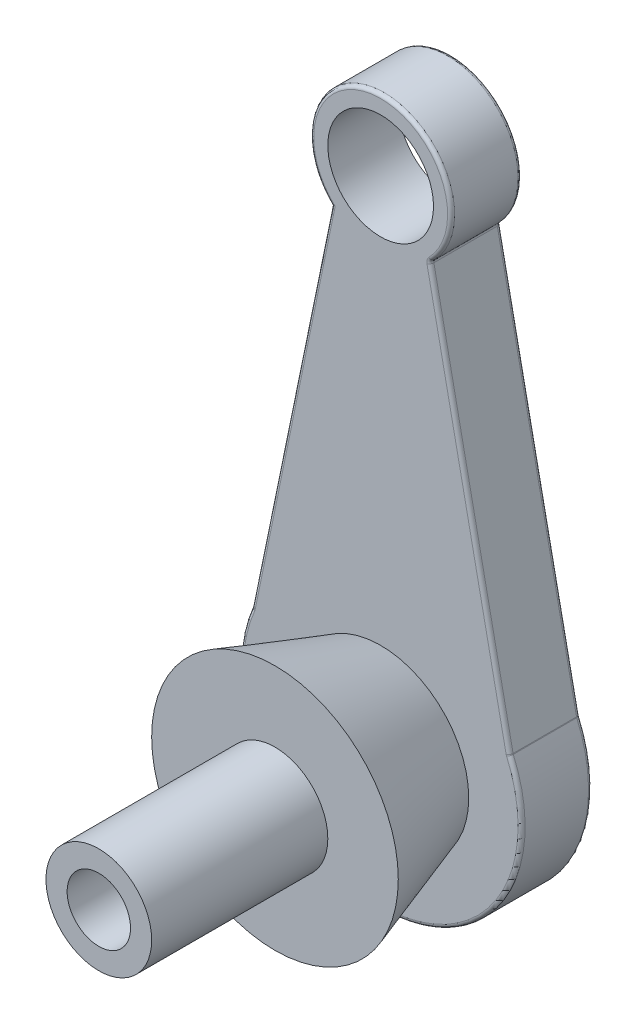
from build123d import *

# Parameters (mm, degrees)
BOSS_EXTRUDE2_DEPTH = 10
SKETCH11_R          = 7.5
CUT_EXTRUDE1_DEPTH  = 11
SKETCH12_R          = 12.5
SKETCH13_R          = 17.5
SKETCH16_R          = 7.5
BOSS_EXTRUDE3_DEPTH = 25
SKETCH17_R          = 13
CUT_EXTRUDE2_DEPTH  = 7.7
FILLET2_R           = 0.5
CUT_EXTRUDE3_REACH  = 44.3
SKETCH18_R          = 4.5


with BuildPart() as part:
    # Sketch10 → Boss-Extrude2 (new body)
    with BuildSketch(Plane.XY):
        with BuildLine():
            Line((-7, 12.658044745), (-18.304628492, -42.341955255))
            ThreePointArc((-18.304628492, -42.341955255), (0, -70.400526826), (18.304628492, -42.341955255))
            Line((18.304628492, -42.341955255), (7, 12.658044745))
            ThreePointArc((7, 12.658044745), (0, 29.799473174), (-7, 12.658044745))
        make_face()
    extrude(amount=-BOSS_EXTRUDE2_DEPTH)

    # Sketch11 → Cut-Extrude1 (cut, through all)
    with BuildSketch(Plane.XY):
        with Locations((0, 19.799473174)):
            Circle(SKETCH11_R)
    extrude(amount=-CUT_EXTRUDE1_DEPTH, mode=Mode.SUBTRACT)

    # Sketch12 → Loft1 section 0
    with BuildSketch(Plane.XY):
        with Locations((0, -50.400526826)):
            Circle(SKETCH12_R)
    # Sketch13 → Loft1 section 1
    with BuildSketch(Plane.XY.offset(15)):
        with Locations((0, -50.400526826)):
            Circle(SKETCH13_R)
    loft()

    # Sketch16 → Boss-Extrude3 (add)
    with BuildSketch(Plane.XY.offset(15)):
        with Locations((0, -50.400526826)):
            Circle(SKETCH16_R)
    extrude(amount=BOSS_EXTRUDE3_DEPTH)

    # Sketch17 → Cut-Extrude2 (cut)
    with BuildSketch(Plane(origin=(0, 0, -10), x_dir=(-1, 0, 0), z_dir=(0, 0, -1))):
        with Locations((0, -50.400526826)):
            Circle(SKETCH17_R)
    extrude(amount=-CUT_EXTRUDE2_DEPTH, mode=Mode.SUBTRACT)

    # Fillet2
    fillet2_edges = [part.edges().sort_by_distance(p)[0] for p in [
        (0, -70.400526826, -10),
        (12.652314246, -14.841955255, -10),
        (0, 29.799473174, -10),
        (12.652314246, -14.841955255, 0),
        (0, -70.400526826, 0),
        (-12.652314246, -14.841955255, 0),
        (0, 29.799473174, 0),
        (-12.652314246, -14.841955255, -10),
        (7, 12.658044745, -5),
        (18.304628492, -42.341955255, -5),
        (-18.304628492, -42.341955255, -5),
    ]]
    fillet(fillet2_edges, radius=FILLET2_R)

    # Sketch18 → Cut-Extrude3 (cut, up to next)
    with BuildSketch(Plane(origin=(0, 0, -2.3), x_dir=(-1, 0, 0), z_dir=(0, 0, -1)), mode=Mode.PRIVATE) as cut_extrude3_sk1:
        with Locations((0, -50.400526826)):
            Circle(SKETCH18_R)
    cut_extrude3_tool1 = extrude(cut_extrude3_sk1.sketch, amount=-CUT_EXTRUDE3_REACH, mode=Mode.PRIVATE) & part.part
    add(cut_extrude3_tool1.solids().sort_by_distance((0, -50.400527, -2.3))[0], mode=Mode.SUBTRACT)


solid = part.part
